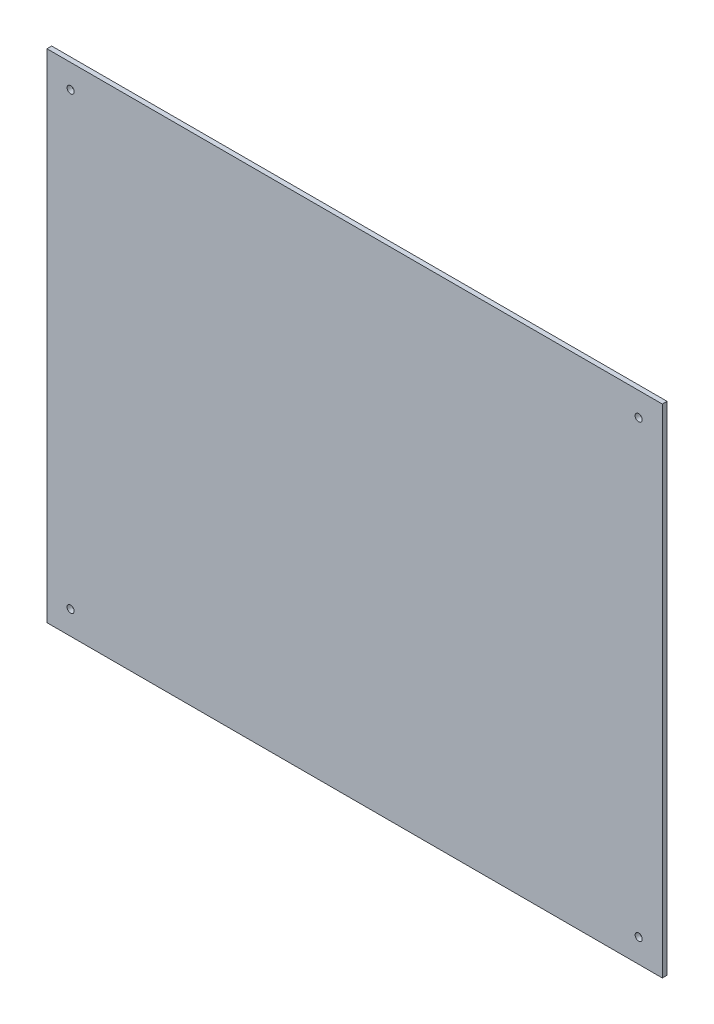
from build123d import *

# Parameters (mm, degrees)
SKETCH_1_W          = 260
SKETCH_1_H          = 210
EXTRUDE_1_DEPTH     = 2
SKETCH_2_R          = 1.5
CUT_EXTRUDE_1_DEPTH = 2


with BuildPart() as part:
    # 草图1 → 凸台-拉伸1 (new body)
    with BuildSketch(Plane.XY):
        with Locations((130, 105)):
            Rectangle(SKETCH_1_W, SKETCH_1_H)
    extrude(amount=EXTRUDE_1_DEPTH)

    # 草图2 → 切除-拉伸1 (cut)
    with BuildSketch(Plane.XY.offset(2)):
        with Locations((10, 200)):
            Circle(SKETCH_2_R)
        with Locations((250, 200)):
            Circle(SKETCH_2_R)
        with Locations((10, 10)):
            Circle(SKETCH_2_R)
        with Locations((250, 10)):
            Circle(SKETCH_2_R)
    extrude(amount=-CUT_EXTRUDE_1_DEPTH, mode=Mode.SUBTRACT)


solid = part.part
